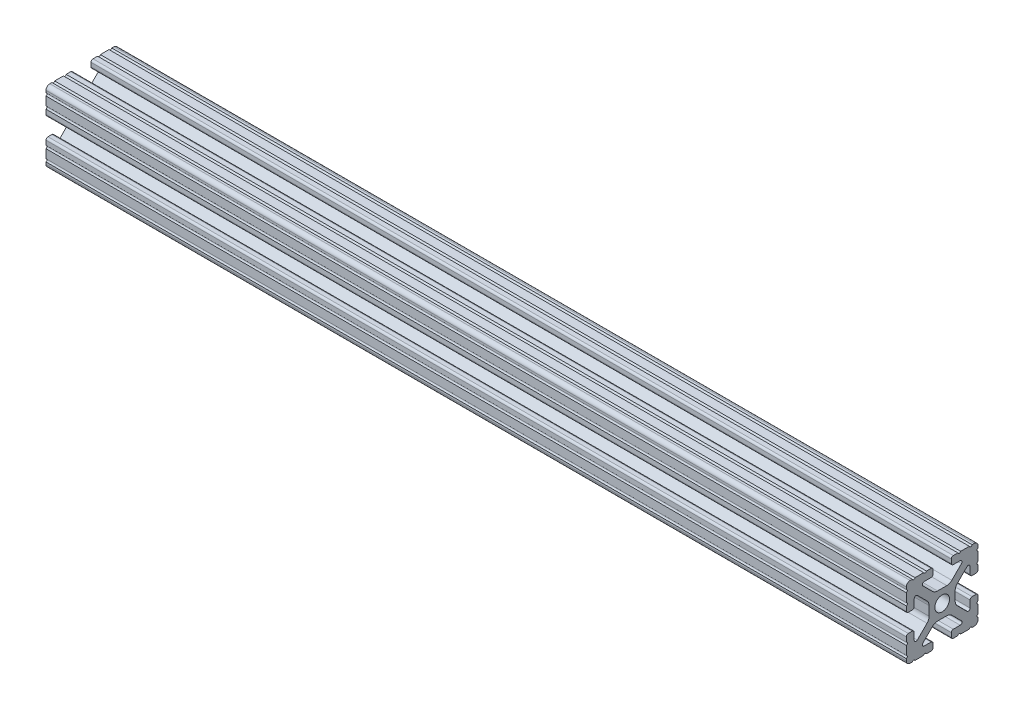
from build123d import *

# Parameters (mm, degrees)
SKETCH2_R           = 2.6035
BOSS_EXTRUDE1_DEPTH = 304.8


with BuildPart() as part:
    # Sketch2 → Boss-Extrude1 (new body)
    with BuildSketch(Plane(origin=(0, 0, 0), x_dir=(0, 0, -1), z_dir=(1, 0, 0))):
        with BuildLine():
            ThreePointArc((14.334948438, 8.074367167), (15.301384825, 7.882131017), (16.120690033, 7.33468878))
            Line((16.120690033, 7.33468878), (19.543976403, 3.911402409))
            ThreePointArc((19.543976403, 3.911402409), (19.684847869, 3.203193724), (19.084457536, 2.802025729))
            Line((19.084457536, 2.802025729), (16.63615869, 2.802025729))
            ThreePointArc((16.63615869, 2.802025729), (16.142839499, 2.59768623), (15.9385, 2.10436704))
            Line((15.9385, 2.10436704), (15.9385, 0.69765869))
            ThreePointArc((15.9385, 0.69765869), (16.142839499, 0.204339499), (16.63615869, 0))
            Line((16.63615869, 0), (18.269856434, 0))
            ThreePointArc((18.269856434, 0), (18.756204355, 0.361269978), (19.242552277, 0))
            Line((19.242552277, 0), (22.318048746, 0))
            ThreePointArc((22.318048746, 0), (22.808739066, 0.376519925), (23.299429386, 0))
            Line((23.299429386, 0), (24.052572236, 0))
            ThreePointArc((24.052572236, 0), (25.005347545, 0.394652455), (25.4, 1.347427764))
            Line((25.4, 1.347427764), (25.4, 2.100570614))
            ThreePointArc((25.4, 2.100570614), (25.023480075, 2.591260934), (25.4, 3.081951254))
            Line((25.4, 3.081951254), (25.4, 6.157447723))
            ThreePointArc((25.4, 6.157447723), (25.038730022, 6.643795645), (25.4, 7.130143566))
            Line((25.4, 7.130143566), (25.4, 8.76384131))
            ThreePointArc((25.4, 8.76384131), (25.195660501, 9.257160501), (24.70234131, 9.4615))
            Line((24.70234131, 9.4615), (23.29563296, 9.4615))
            ThreePointArc((23.29563296, 9.4615), (22.80231377, 9.257160501), (22.597974271, 8.76384131))
            Line((22.597974271, 8.76384131), (22.597974271, 6.315542464))
            ThreePointArc((22.597974271, 6.315542464), (22.196806276, 5.715152131), (21.488597591, 5.856023597))
            Line((21.488597591, 5.856023597), (18.06531122, 9.279309967))
            ThreePointArc((18.06531122, 9.279309967), (17.517868983, 10.098615175), (17.325632833, 11.065051562))
            Line((17.325632833, 11.065051562), (17.325632833, 14.334948438))
            ThreePointArc((17.325632833, 14.334948438), (17.517868983, 15.301384825), (18.06531122, 16.120690033))
            Line((18.06531122, 16.120690033), (21.488597591, 19.543976403))
            ThreePointArc((21.488597591, 19.543976403), (22.196806276, 19.684847869), (22.597974271, 19.084457536))
            Line((22.597974271, 19.084457536), (22.597974271, 16.63615869))
            ThreePointArc((22.597974271, 16.63615869), (22.80231377, 16.142839499), (23.29563296, 15.9385))
            Line((23.29563296, 15.9385), (24.70234131, 15.9385))
            ThreePointArc((24.70234131, 15.9385), (25.195660501, 16.142839499), (25.4, 16.63615869))
            Line((25.4, 16.63615869), (25.4, 18.269856434))
            ThreePointArc((25.4, 18.269856434), (25.038730022, 18.756204355), (25.4, 19.242552277))
            Line((25.4, 19.242552277), (25.4, 22.318048746))
            ThreePointArc((25.4, 22.318048746), (25.023480075, 22.808739066), (25.4, 23.299429386))
            Line((25.4, 23.299429386), (25.4, 24.052572236))
            ThreePointArc((25.4, 24.052572236), (25.005347545, 25.005347545), (24.052572236, 25.4))
            Line((24.052572236, 25.4), (23.299429386, 25.4))
            ThreePointArc((23.299429386, 25.4), (22.808739066, 25.023480075), (22.318048746, 25.4))
            Line((22.318048746, 25.4), (19.242552277, 25.4))
            ThreePointArc((19.242552277, 25.4), (18.756204355, 25.038730022), (18.269856434, 25.4))
            Line((18.269856434, 25.4), (16.63615869, 25.4))
            ThreePointArc((16.63615869, 25.4), (16.142839499, 25.195660501), (15.9385, 24.70234131))
            Line((15.9385, 24.70234131), (15.9385, 23.29563296))
            ThreePointArc((15.9385, 23.29563296), (16.142839499, 22.80231377), (16.63615869, 22.597974271))
            Line((16.63615869, 22.597974271), (19.084457536, 22.597974271))
            ThreePointArc((19.084457536, 22.597974271), (19.684847869, 22.196806276), (19.543976403, 21.488597591))
            Line((19.543976403, 21.488597591), (16.120690033, 18.06531122))
            ThreePointArc((16.120690033, 18.06531122), (15.301384825, 17.517868983), (14.334948438, 17.325632833))
            Line((14.334948438, 17.325632833), (11.065051562, 17.325632833))
            ThreePointArc((11.065051562, 17.325632833), (10.098615175, 17.517868983), (9.279309967, 18.06531122))
            Line((9.279309967, 18.06531122), (5.856023597, 21.488597591))
            ThreePointArc((5.856023597, 21.488597591), (5.715152131, 22.196806276), (6.315542464, 22.597974271))
            Line((6.315542464, 22.597974271), (8.76384131, 22.597974271))
            ThreePointArc((8.76384131, 22.597974271), (9.257160501, 22.80231377), (9.4615, 23.29563296))
            Line((9.4615, 23.29563296), (9.4615, 24.70234131))
            ThreePointArc((9.4615, 24.70234131), (9.257160501, 25.195660501), (8.76384131, 25.4))
            Line((8.76384131, 25.4), (7.130143566, 25.4))
            ThreePointArc((7.130143566, 25.4), (6.643795645, 25.038730022), (6.157447723, 25.4))
            Line((6.157447723, 25.4), (3.081951254, 25.4))
            ThreePointArc((3.081951254, 25.4), (2.591260934, 25.023480075), (2.100570614, 25.4))
            Line((2.100570614, 25.4), (1.347427764, 25.4))
            ThreePointArc((1.347427764, 25.4), (0.394652455, 25.005347545), (0, 24.052572236))
            Line((0, 24.052572236), (0, 23.299429386))
            ThreePointArc((0, 23.299429386), (0.376519925, 22.808739066), (0, 22.318048746))
            Line((0, 22.318048746), (0, 19.242552277))
            ThreePointArc((0, 19.242552277), (0.361269978, 18.756204355), (0, 18.269856434))
            Line((0, 18.269856434), (0, 16.63615869))
            ThreePointArc((0, 16.63615869), (0.204339499, 16.142839499), (0.69765869, 15.9385))
            Line((0.69765869, 15.9385), (2.10436704, 15.9385))
            ThreePointArc((2.10436704, 15.9385), (2.59768623, 16.142839499), (2.802025729, 16.63615869))
            Line((2.802025729, 16.63615869), (2.802025729, 19.084457536))
            ThreePointArc((2.802025729, 19.084457536), (3.203193724, 19.684847869), (3.911402409, 19.543976403))
            Line((3.911402409, 19.543976403), (7.33468878, 16.120690033))
            ThreePointArc((7.33468878, 16.120690033), (7.882131017, 15.301384825), (8.074367167, 14.334948438))
            Line((8.074367167, 14.334948438), (8.074367167, 11.065051562))
            ThreePointArc((8.074367167, 11.065051562), (7.882131017, 10.098615175), (7.33468878, 9.279309967))
            Line((7.33468878, 9.279309967), (3.911402409, 5.856023597))
            ThreePointArc((3.911402409, 5.856023597), (3.203193724, 5.715152131), (2.802025729, 6.315542464))
            Line((2.802025729, 6.315542464), (2.802025729, 8.76384131))
            ThreePointArc((2.802025729, 8.76384131), (2.59768623, 9.257160501), (2.10436704, 9.4615))
            Line((2.10436704, 9.4615), (0.69765869, 9.4615))
            ThreePointArc((0.69765869, 9.4615), (0.204339499, 9.257160501), (0, 8.76384131))
            Line((0, 8.76384131), (0, 7.130143566))
            ThreePointArc((0, 7.130143566), (0.361269978, 6.643795645), (0, 6.157447723))
            Line((0, 6.157447723), (0, 3.081951254))
            ThreePointArc((0, 3.081951254), (0.376519925, 2.591260934), (0, 2.100570614))
            Line((0, 2.100570614), (0, 1.347427764))
            ThreePointArc((0, 1.347427764), (0.394652455, 0.394652455), (1.347427764, 0))
            Line((1.347427764, 0), (2.100570614, 0))
            ThreePointArc((2.100570614, 0), (2.591260934, 0.376519925), (3.081951254, 0))
            Line((3.081951254, 0), (6.157447723, 0))
            ThreePointArc((6.157447723, 0), (6.643795645, 0.361269978), (7.130143566, 0))
            Line((7.130143566, 0), (8.76384131, 0))
            ThreePointArc((8.76384131, 0), (9.257160501, 0.204339499), (9.4615, 0.69765869))
            Line((9.4615, 0.69765869), (9.4615, 2.10436704))
            ThreePointArc((9.4615, 2.10436704), (9.257160501, 2.59768623), (8.76384131, 2.802025729))
            Line((8.76384131, 2.802025729), (6.315542464, 2.802025729))
            ThreePointArc((6.315542464, 2.802025729), (5.715152131, 3.203193724), (5.856023597, 3.911402409))
            Line((5.856023597, 3.911402409), (9.279309967, 7.33468878))
            ThreePointArc((9.279309967, 7.33468878), (10.098615175, 7.882131017), (11.065051562, 8.074367167))
            Line((11.065051562, 8.074367167), (14.334948438, 8.074367167))
        make_face()
        with Locations((12.7, 12.7)):
            Circle(SKETCH2_R, mode=Mode.SUBTRACT)
    extrude(amount=BOSS_EXTRUDE1_DEPTH)


with BuildPart() as part_1:
    # Body-Move/Copy1: moved
    add(part.part.moved(Location((-150.058747395, 28.75970044, 59.645039801))))


solid = part_1.part
